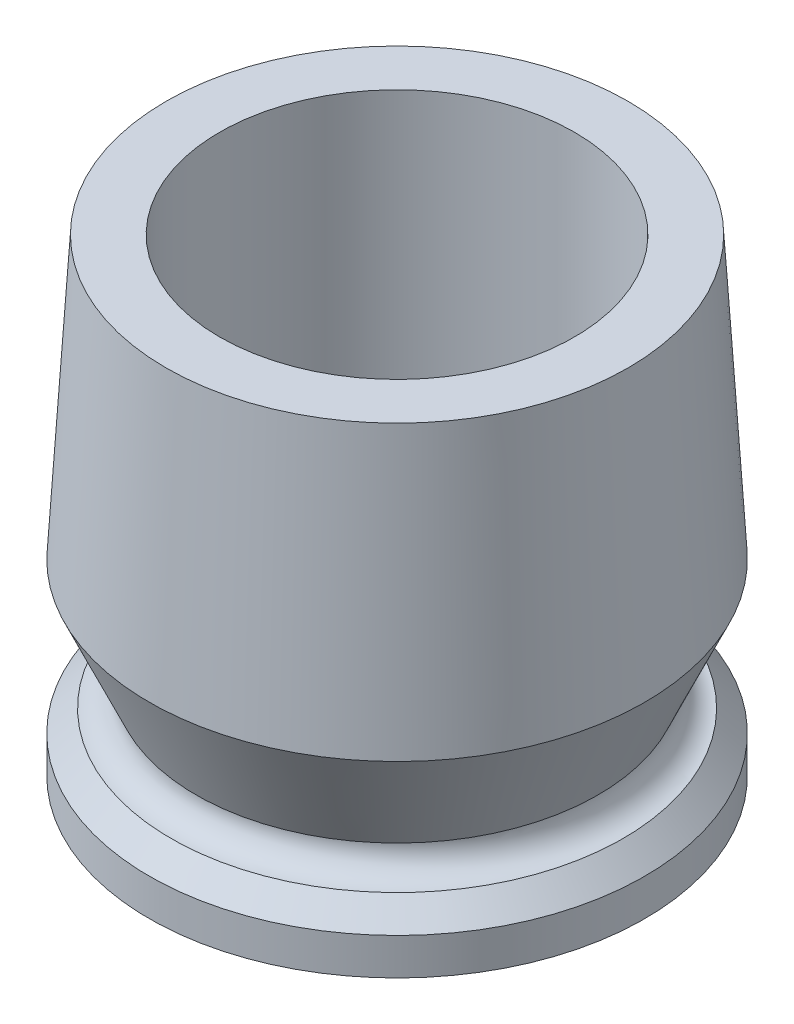
from build123d import *

# Parameters (mm, degrees)
SKETCH2_R               = 26.5
CUT_EXTRUDE1_DEPTH      = 1
CUT_EXTRUDE1_DEPTH_BACK = 71


with BuildPart() as part:
    # Sketch1 → Revolve1 (revolve)
    with BuildSketch(Plane.XY):
        with BuildLine():
            Line((0, 0), (0, 70))
            Line((0, 70), (34.5, 70))
            Line((34.5, 70), (37, 28))
            Line((37, 28), (30, 12.5))
            ThreePointArc((30, 12.5), (31.098349571, 9.848349571), (33.75, 8.75))
            Line((33.75, 8.75), (37, 5.5))
            Line((37, 5.5), (37, 0))
            Line((37, 0), (0, 0))
        make_face()
    revolve(axis=Axis((0, 0, 0), (0, 1, 0)))

    # Sketch2 → Cut-Extrude1 (cut, two sides)
    with BuildSketch(Plane(origin=(0, 70, 0), x_dir=(1, 0, 0), z_dir=(0, 1, 0))) as cut_extrude1_sk:
        Circle(SKETCH2_R)
    extrude(amount=CUT_EXTRUDE1_DEPTH, mode=Mode.SUBTRACT)
    extrude(cut_extrude1_sk.sketch, amount=-CUT_EXTRUDE1_DEPTH_BACK, mode=Mode.SUBTRACT)


solid = part.part
